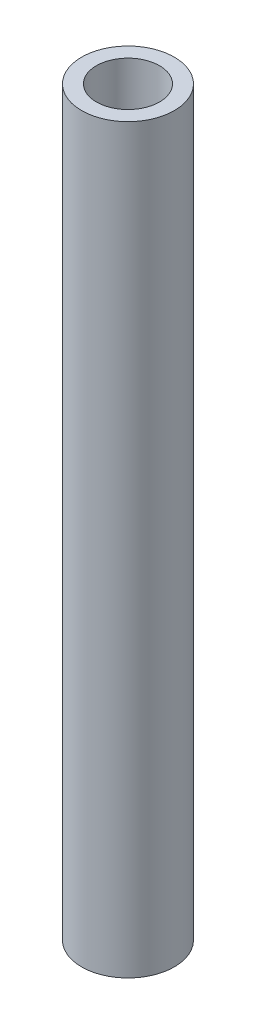
from build123d import *

# Parameters (mm, degrees)
SKETCH1_R           = 0.3125
SKETCH1_R_2         = 0.2125
BOSS_EXTRUDE1_DEPTH = 5


with BuildPart() as part:
    # Sketch1 → Boss-Extrude1 (new body)
    with BuildSketch(Plane(origin=(0, 0, 0), x_dir=(1, 0, 0), z_dir=(0, 1, 0))):
        Circle(SKETCH1_R)
        Circle(SKETCH1_R_2, mode=Mode.SUBTRACT)
    extrude(amount=BOSS_EXTRUDE1_DEPTH)


solid = part.part
